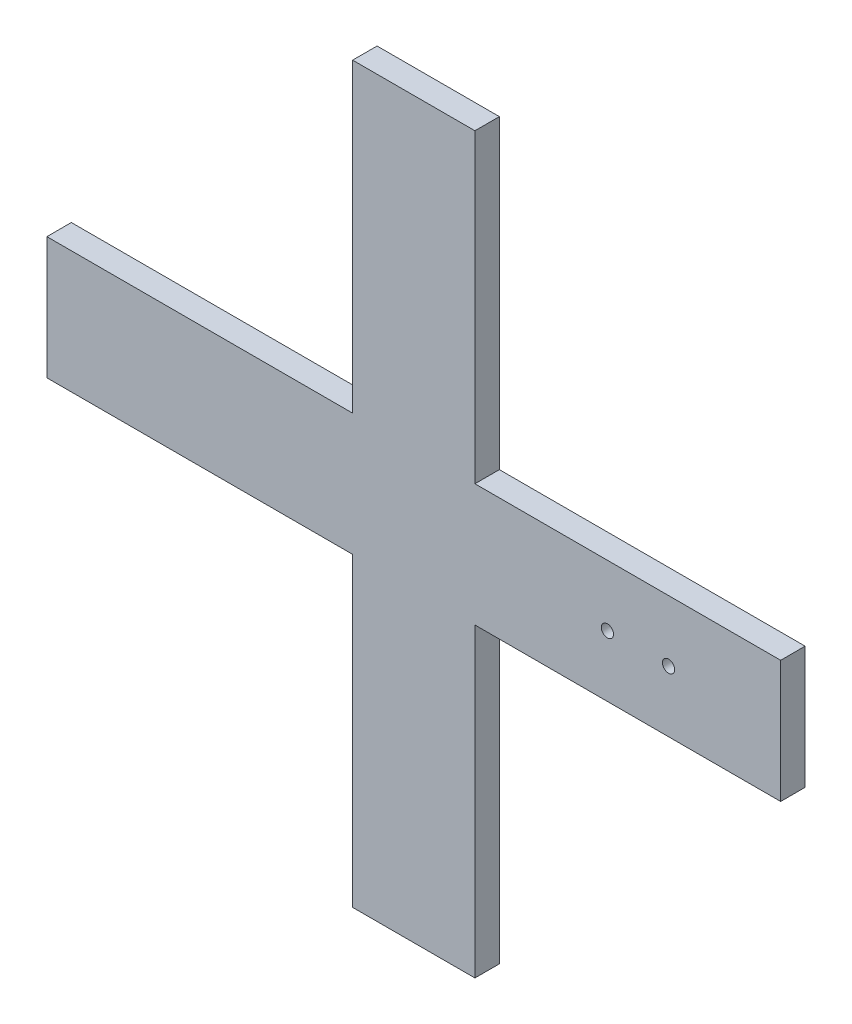
from build123d import *

# Parameters (mm, degrees)
ESBO_O1_R                = 1.5
RESSALTO_EXTRUS_O1_DEPTH = 6


with BuildPart() as part:
    # Esboço1 → Ressalto-extrusão1 (new body)
    with BuildSketch(Plane.XY):
        Polygon((105, 105), (105, 180), (75, 180), (75, 105), (0, 105), (0, 75), (75, 75), (75, 0), (105, 0), (105, 75), (180, 75), (180, 105), align=None)
        with Locations((137.5, 90)):
            Circle(ESBO_O1_R, mode=Mode.SUBTRACT)
        with Locations((152.5, 90)):
            Circle(ESBO_O1_R, mode=Mode.SUBTRACT)
    extrude(amount=RESSALTO_EXTRUS_O1_DEPTH)


solid = part.part
